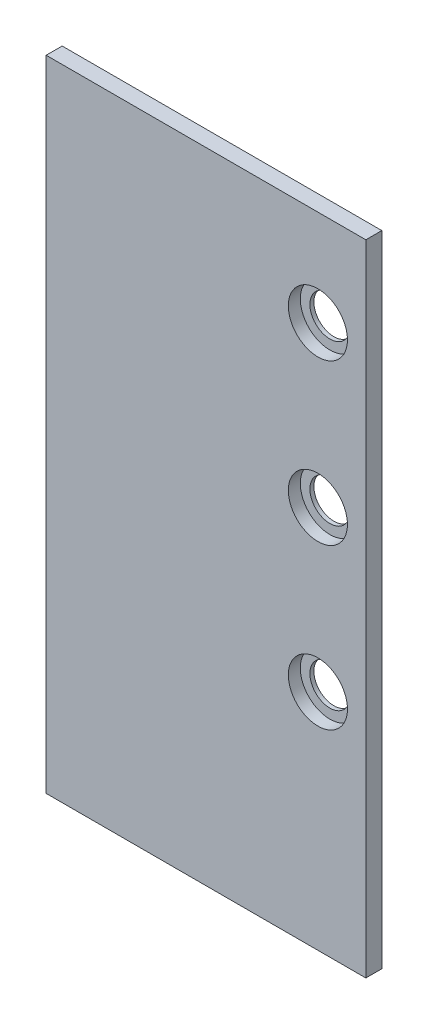
from build123d import *

# Parameters (mm, degrees)
BOSS_EXTRUDE1_DEPTH = 3.175
SKETCH4_R           = 11.7475
CUT_EXTRUDE1_DEPTH  = 4.7625
SKETCH5_R           = 7.9375
CUT_EXTRUDE2_DEPTH  = 2.5875
LPATTERN1_COUNT     = 3
LPATTERN1_PITCH     = 63.5


with BuildPart() as part:
    # Sketch3 → Boss-Extrude1 (new body, symmetric)
    with BuildSketch(Plane(origin=(65.549733265, 163.86644962, 0), x_dir=(1, 0, 0), z_dir=(0, 0, 1))):
        Polygon((19.05, -76.2), (0, -76.2), (-107.95, -76.2), (-107.95, 177.8), (19.05, 177.8), align=None)
    extrude(amount=BOSS_EXTRUDE1_DEPTH, both=True)

    # Sketch4 → Cut-Extrude1 (cut)
    with BuildSketch(Plane.XY.offset(3.175)):
        with Locations((65.549733265, 176.56644962)):
            Circle(SKETCH4_R)
    cut_extrude1 = extrude(amount=-CUT_EXTRUDE1_DEPTH, mode=Mode.SUBTRACT)

    # Sketch5 → Cut-Extrude2 (cut, through all)
    with BuildSketch(Plane.XY.offset(-1.5875)):
        with Locations((65.549733265, 176.56644962)):
            Circle(SKETCH5_R)
    cut_extrude2 = extrude(amount=-CUT_EXTRUDE2_DEPTH, mode=Mode.SUBTRACT)

    # LPattern1: Cut-Extrude1, Cut-Extrude2 ×3
    with Locations(*[(0, i * LPATTERN1_PITCH, 0) for i in range(1, LPATTERN1_COUNT)]):
        add(cut_extrude1, mode=Mode.SUBTRACT)
        add(cut_extrude2, mode=Mode.SUBTRACT)


solid = part.part
